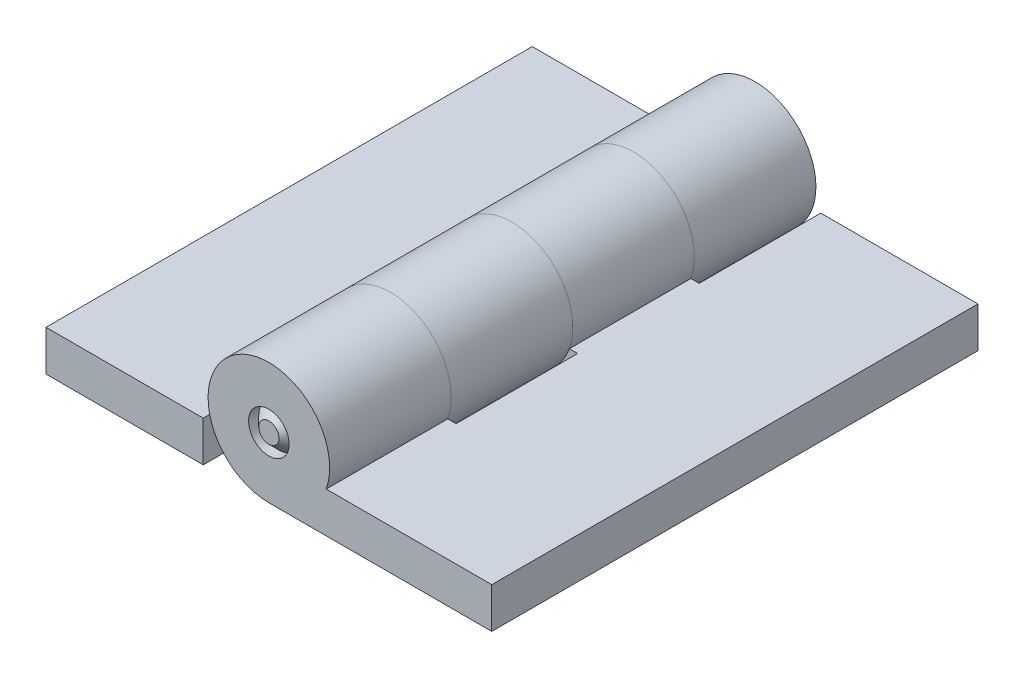
from build123d import *

# Parameters (mm, degrees)
SKETCH1_R            = 1.5875
EXTRUDE1_DEPTH       = 19.05
SKETCH1_W            = 12.319
SKETCH1_H            = 3.175
EXTRUDE1_2_DEPTH     = 19.05
SKETCH10_W           = 10.287
SKETCH10_H           = 9.525
EXTRUDE6_DEPTH       = 5.7625
EXTRUDE6_DEPTH_BACK  = 5.7625
SKETCH11_R           = 1.5875
EXTRUDE7_DEPTH       = 9.525
SKETCH12_R           = 1.5875
EXTRUDE8_DEPTH       = 9.525
SKETCH19_W           = 34.925
SKETCH19_H           = 1.5875
EXTRUDE23_DEPTH      = 5.7625
EXTRUDE23_DEPTH_BACK = 5.7625
CHAMFER1_SIZE        = 0.79375


with BuildPart() as part:
    # Sketch1 → Extrude1 (new body, symmetric)
    with BuildSketch(Plane.XY):
        with BuildLine():
            Line((17.4625, -4.7625), (0, -4.7625))
            ThreePointArc((0, -4.7625), (-2.749630657, 3.888564967), (4.490128061, -1.5875))
            Line((4.490128061, -1.5875), (17.4625, -1.5875))
            Line((17.4625, -1.5875), (17.4625, -4.7625))
        make_face()
        Circle(SKETCH1_R, mode=Mode.SUBTRACT)
    extrude(amount=EXTRUDE1_DEPTH, both=True)

    # Sketch10 → Extrude6 (cut, two sides)
    with BuildSketch(Plane(origin=(0, 0, 0), x_dir=(1, 0, 0), z_dir=(0, 1, 0))) as extrude6_sk:
        with Locations((0, 14.2875)):
            Rectangle(SKETCH10_W, SKETCH10_H)
        with Locations((0, -4.7625)):
            Rectangle(SKETCH10_W, SKETCH10_H)
    extrude(amount=EXTRUDE6_DEPTH, mode=Mode.SUBTRACT)
    extrude(extrude6_sk.sketch, amount=-EXTRUDE6_DEPTH_BACK, mode=Mode.SUBTRACT)


with BuildPart() as body_2:
    # Sketch1 → Extrude1 2 (new body, symmetric)
    with BuildSketch(Plane.XY):
        with Locations((-11.303, -3.175)):
            Rectangle(SKETCH1_W, SKETCH1_H)
    extrude(amount=EXTRUDE1_2_DEPTH, both=True)

    # Sketch11 → Extrude7 (add)
    with BuildSketch(Plane.XY.offset(-19.05)):
        with BuildLine():
            Line((0, -4.7625), (-5.1435, -4.7625))
            Line((-5.1435, -4.7625), (-5.1435, -1.5875))
            Line((-5.1435, -1.5875), (-4.490128061, -1.5875))
            ThreePointArc((-4.490128061, -1.5875), (2.749630657, 3.888564967), (0, -4.7625))
        make_face()
        Circle(SKETCH11_R, mode=Mode.SUBTRACT)
    extrude(amount=EXTRUDE7_DEPTH)

    # Sketch12 → Extrude8 (add)
    with BuildSketch(Plane.XY):
        with BuildLine():
            Line((-5.1435, -4.7625), (0, -4.7625))
            ThreePointArc((0, -4.7625), (2.749630657, 3.888564967), (-4.490128061, -1.5875))
            Line((-4.490128061, -1.5875), (-5.1435, -1.5875))
            Line((-5.1435, -1.5875), (-5.1435, -4.7625))
        make_face()
        Circle(SKETCH12_R, mode=Mode.SUBTRACT)
    extrude(amount=EXTRUDE8_DEPTH)


with BuildPart() as body_3:
    # Sketch6 → Revolve1 (revolve)
    with BuildSketch(Plane(origin=(0, 0, 0), x_dir=(1, 0, 0), z_dir=(0, 1, 0))):
        with BuildLine():
            Line((-3.175, 19.05), (-1.5875, 19.05))
            Line((-1.5875, 19.05), (-1.5875, -19.05))
            Line((-1.5875, -19.05), (-3.175, -19.05))
            ThreePointArc((-3.175, -19.05), (-1.774878957, -20.218507914), (0, -20.6375))
            Line((0, -20.6375), (0, 20.6375))
            ThreePointArc((0, 20.6375), (-1.774878957, 20.218507914), (-3.175, 19.05))
        make_face()
    revolve(axis=Axis((0, 0, -20.6375), (0, 0, 1)))

    # Sketch19 → Extrude23 (cut, two sides)
    with BuildSketch(Plane(origin=(0, 0, 0), x_dir=(1, 0, 0), z_dir=(0, 1, 0))) as extrude23_sk:
        with Locations((0, -19.84375)):
            Rectangle(SKETCH19_W, SKETCH19_H)
    extrude(amount=EXTRUDE23_DEPTH, mode=Mode.SUBTRACT)
    extrude(extrude23_sk.sketch, amount=-EXTRUDE23_DEPTH_BACK, mode=Mode.SUBTRACT)

    # Chamfer1
    chamfer1_edges = [body_3.edges().sort_by_distance(p)[0] for p in [
        (1.5875, 0, 19.05),
    ]]
    chamfer(chamfer1_edges, length=CHAMFER1_SIZE)


solid = Compound([part.part, body_2.part, body_3.part])
